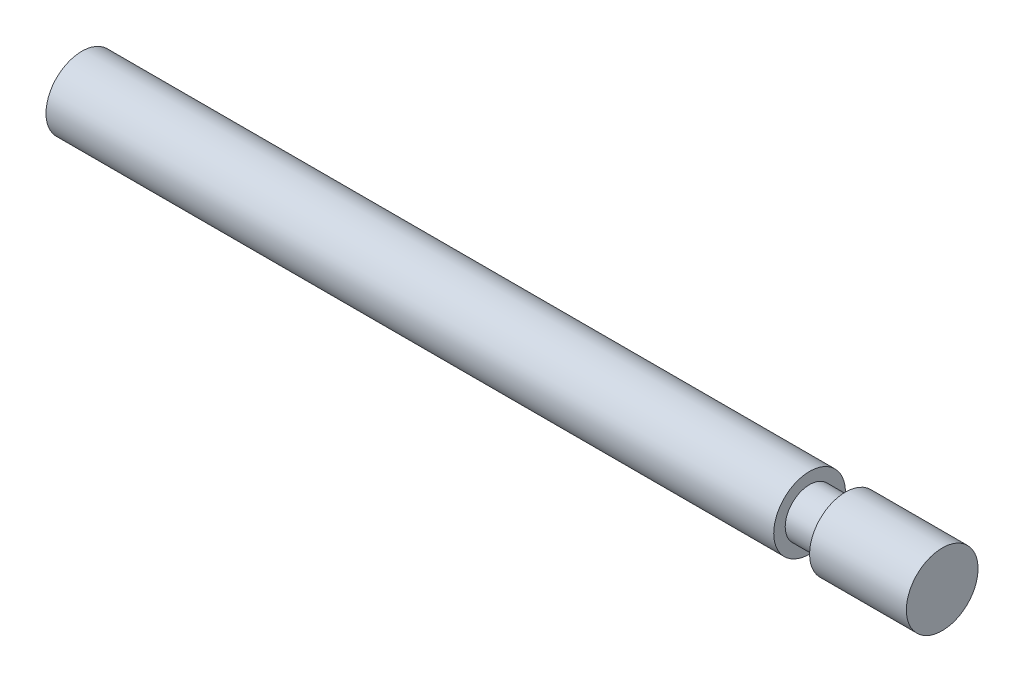
from build123d import *


with BuildPart() as part:
    # Esboço1 → Revolução1 (revolve)
    with BuildSketch(Plane(origin=(0, 0, 0), x_dir=(1, 0, 0), z_dir=(0, 1, 0))):
        Polygon((-60, 0), (-60, -2.5), (-9.25, -2.5), (-9.25, -1.7), (-6.75, -1.7), (-6.75, -2.5), (0, -2.5), (0, 0), align=None)
    revolve(axis=Axis((-67.033685718, 0, 0), (1, 0, 0)))


solid = part.part
